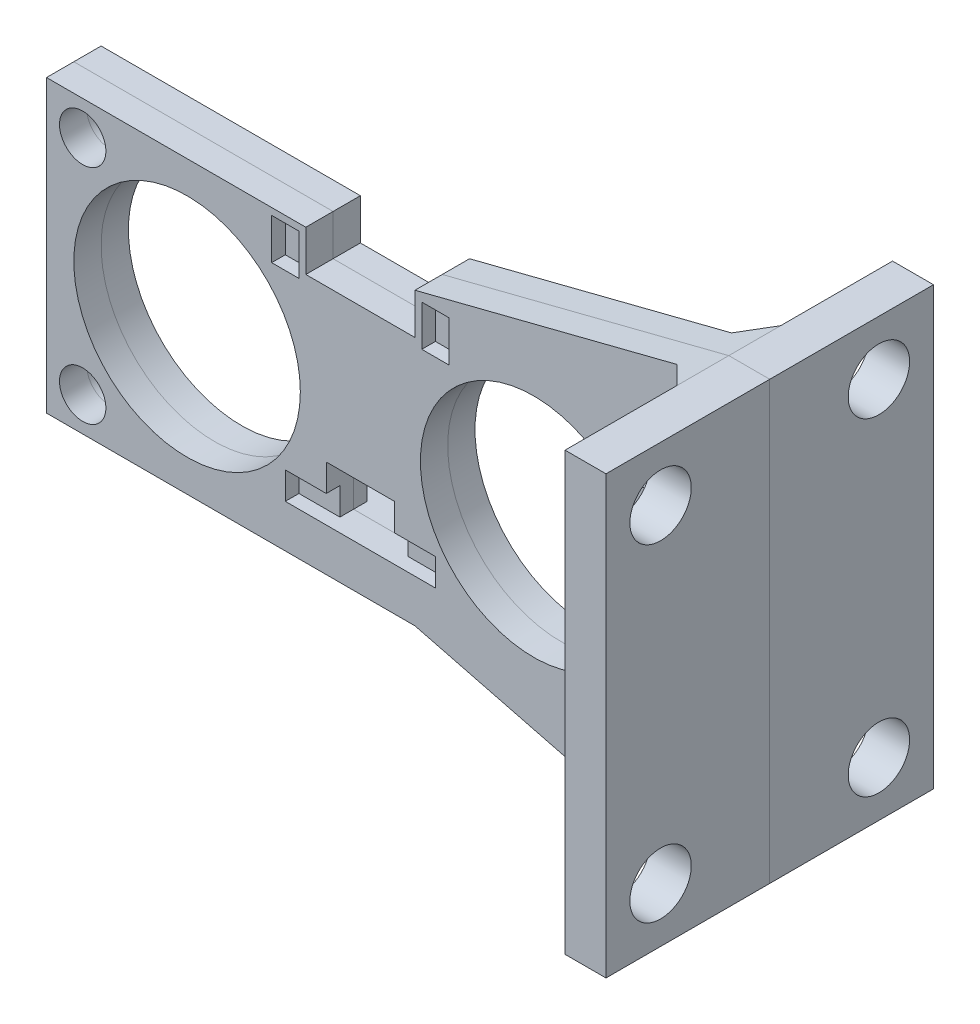
from build123d import *

# Parameters (mm, degrees)
SKETCH_1_W          = 46
SKETCH_1_H          = 21.3
EXTRUDE_1_DEPTH     = 2
SKETCH_2_R          = 8.3
CUT_EXTRUDE_1_DEPTH = 3
SKETCH_3_W          = 8
SKETCH_3_H          = 3
CUT_EXTRUDE_2_DEPTH = 3
SKETCH_4_W          = 5
SKETCH_4_H          = 4
CUT_EXTRUDE_3_DEPTH = 3
SKETCH_5_W          = 3
SKETCH_5_H          = 2
SKETCH_5_W_2        = 2
SKETCH_5_H_2        = 3
CUT_EXTRUDE_4_DEPTH = 1
HOLE_WIZARD_M3_1_D  = 3.4
SKETCH_13_W         = 2
SKETCH_13_H         = 21.3
EXTRUDE_5_DEPTH     = 2
SKETCH_9_W          = 3
SKETCH_9_H          = 32
EXTRUDE_3_DEPTH     = 12
HOLE_WIZARD_M4_1_D  = 4.5
EXTRUDE_4_DEPTH     = 2
CHAMFER_1_SIZE      = 1.8


with BuildPart() as part:
    # 草圖1 → 填料-伸長1 (new body)
    with BuildSketch(Plane.XY):
        Rectangle(SKETCH_1_W, SKETCH_1_H)
    extrude(amount=EXTRUDE_1_DEPTH)

    # 草圖2 → 除料-伸長1 (cut, through all)
    with BuildSketch(Plane.XY.offset(2)):
        with Locations((-12.7, 0)):
            Circle(SKETCH_2_R)
        with Locations((12.7, 0)):
            Circle(SKETCH_2_R)
    extrude(amount=-CUT_EXTRUDE_1_DEPTH, mode=Mode.SUBTRACT)

    # 草圖3 → 除料-伸長2 (cut, through all)
    with BuildSketch(Plane.XY.offset(2)):
        with Locations((0, 9.15)):
            Rectangle(SKETCH_3_W, SKETCH_3_H)
    extrude(amount=-CUT_EXTRUDE_2_DEPTH, mode=Mode.SUBTRACT)

    # 草圖4 → 除料-伸長3 (cut, through all)
    with BuildSketch(Plane.XY.offset(2)):
        with Locations((0, -5.5)):
            Rectangle(SKETCH_4_W, SKETCH_4_H)
    extrude(amount=-CUT_EXTRUDE_3_DEPTH, mode=Mode.SUBTRACT)

    # 草圖5 → 除料-伸長4 (cut)
    with BuildSketch(Plane.XY.offset(2)):
        with Locations((4, -6.5)):
            Rectangle(SKETCH_5_W, SKETCH_5_H)
        with Locations((-5.5, 8.65)):
            Rectangle(SKETCH_5_W_2, SKETCH_5_H_2)
        with Locations((5.5, 8.65)):
            Rectangle(SKETCH_5_W_2, SKETCH_5_H_2)
        with Locations((-4, -6.5)):
            Rectangle(SKETCH_5_W, SKETCH_5_H)
    extrude(amount=-CUT_EXTRUDE_4_DEPTH, mode=Mode.SUBTRACT)

    # M3 餘隙孔1 (through all)
    with Locations(Plane.XY.offset(2)):
        with Locations((20.35, 8.15), (-20.35, -8.15), (-20.35, 8.15), (20.35, -8.15)):
            Hole(HOLE_WIZARD_M3_1_D / 2)

    # 草圖13 → 填料-伸長5 (add)
    with BuildSketch(Plane(origin=(23, 0, 0), x_dir=(0, 0, -1), z_dir=(1, 0, 0))):
        with Locations((-1, 0)):
            Rectangle(SKETCH_13_W, SKETCH_13_H)
    extrude(amount=EXTRUDE_5_DEPTH)

    # 草圖9 → 填料-伸長3 (add)
    with BuildSketch(Plane.XY):
        with Locations((26.5, 0)):
            Rectangle(SKETCH_9_W, SKETCH_9_H)
    extrude(amount=EXTRUDE_3_DEPTH)

    # M4 餘隙孔1 (through all)
    with Locations(Plane.ZY.offset(-25)):
        with Locations((8, 12), (8, -12)):
            Hole(HOLE_WIZARD_M4_1_D / 2)

    # 草圖12 → 填料-伸長4 (add)
    with BuildSketch(Plane.XY):
        Polygon((25, 16), (4, 10.65), (25, 10.65), align=None)
    extrude_4 = extrude(amount=EXTRUDE_4_DEPTH)

    # 鏡射1: 填料-伸長4 across plane
    add(extrude_4.mirror(Plane.ZX))

    # 導角1
    chamfer_1_edges = [part.edges().sort_by_distance(p)[0] for p in [
        (25, 0, 2),
    ]]
    chamfer(chamfer_1_edges, length=CHAMFER_1_SIZE)


with BuildPart() as body_2:
    # 鏡射2: mirrored copy
    add(part.part.mirror(Plane.XY))


solid = Compound([part.part, body_2.part])
